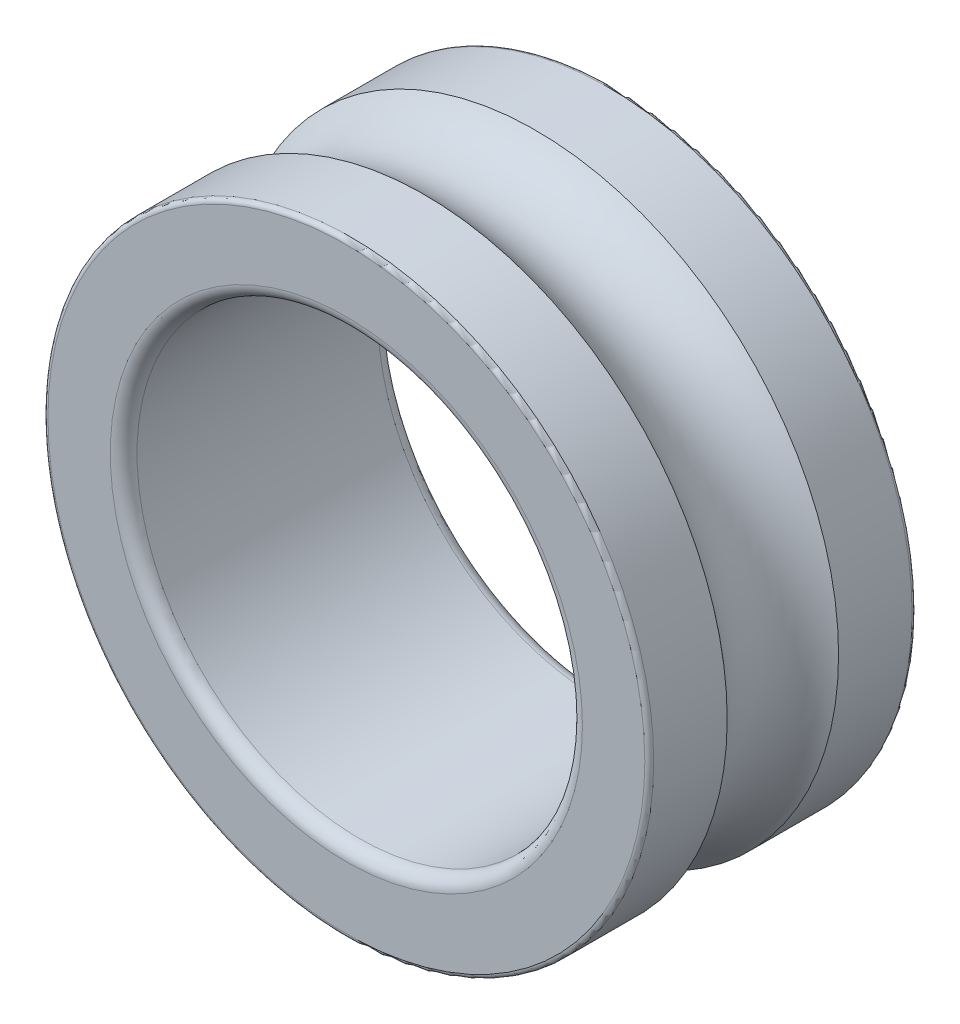
from build123d import *

# Parameters (mm, degrees)
SKETCH2_W = 3.5
SKETCH2_H = 3.6
FILLET1_R = 0.2
FILLET2_R = 0.6


with BuildPart() as part:
    # Sketch2 → Revolve1 (revolve)
    with BuildSketch(Plane(origin=(0, 0, 0), x_dir=(0, 0, -1), z_dir=(1, 0, 0))):
        with Locations((-4.25, 5.05)):
            Rectangle(SKETCH2_W, SKETCH2_H)
        with BuildLine():
            ThreePointArc((2.5, 6.85), (0, 5.647498436), (-2.5, 6.85))
            Line((-2.5, 6.85), (-2.5, 3.25))
            Line((-2.5, 3.25), (2.5, 3.25))
            Line((2.5, 3.25), (2.5, 6.85))
        make_face()
        with Locations((4.25, 5.05)):
            Rectangle(SKETCH2_W, SKETCH2_H)
    revolve(axis=Axis((0, -6.75, 6), (0, 0, -1)))

    # Fillet1
    fillet1_edges = [part.edges().sort_by_distance(p)[0] for p in [
        (0, -20.35, 6),
        (0, -20.35, -6),
    ]]
    fillet(fillet1_edges, radius=FILLET1_R)

    # Fillet2
    fillet2_edges = [part.edges().sort_by_distance(p)[0] for p in [
        (0, -16.75, -6),
        (0, -16.75, 6),
    ]]
    fillet(fillet2_edges, radius=FILLET2_R)


solid = part.part
